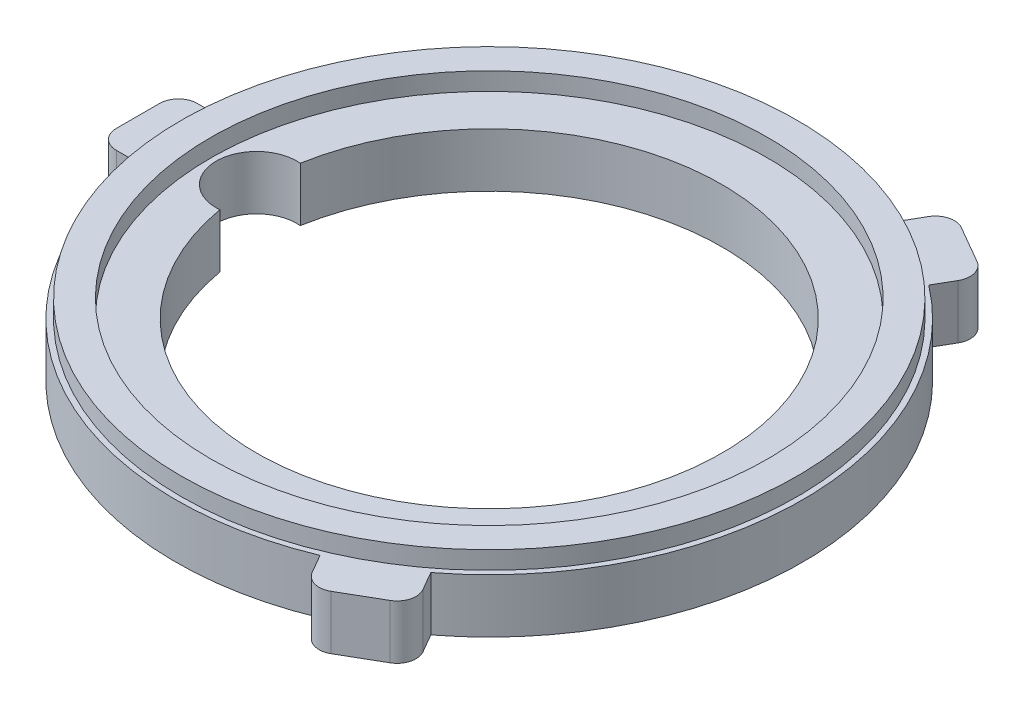
from build123d import *

# Parameters (mm, degrees)
SKIZZE1_R                       = 5.8
AUFSATZ_LINEAR_AUSTRAGEN1_DEPTH = 1
SKIZZE1_3_W                     = 1.261937381
SKIZZE1_3_H                     = 1.5
AUFSATZ_LINEAR_AUSTRAGEN2_DEPTH = 1
SKIZZE4_R                       = 4.304974062
SCHNITT_LINEAR_AUSTRAGEN1_DEPTH = 1
SKIZZE5_R                       = 0.747652737
SCHNITT_LINEAR_AUSTRAGEN2_DEPTH = 1
KREISMUSTER1_COUNT              = 3
VERRUNDUNG2_R                   = 0.35
SKIZZE6_R                       = 5.7
SKIZZE6_R_2                     = 5.1526268
AUFSATZ_LINEAR_AUSTRAGEN3_DEPTH = 0.33


with BuildPart() as part:
    # Skizze1 → Aufsatz-Linear austragen1 (new body)
    with BuildSketch(Plane(origin=(0, 0, 0), x_dir=(1, 0, 0), z_dir=(0, 1, 0))):
        Circle(SKIZZE1_R)
    extrude(amount=AUFSATZ_LINEAR_AUSTRAGEN1_DEPTH)

    # Skizze1_3 → Aufsatz-Linear austragen2 (add)
    with BuildSketch(Plane(origin=(0, 0, 0), x_dir=(1, 0, 0), z_dir=(0, 1, 0))):
        with Locations((-5.86903131, 0)):
            Rectangle(SKIZZE1_3_W, SKIZZE1_3_H)
    aufsatz_linear_austragen2 = extrude(amount=AUFSATZ_LINEAR_AUSTRAGEN2_DEPTH)

    # Skizze4 → Schnitt-Linear austragen1 (cut)
    with BuildSketch(Plane(origin=(0, 1, 0), x_dir=(1, 0, 0), z_dir=(0, 1, 0))):
        Circle(SKIZZE4_R)
    extrude(amount=-SCHNITT_LINEAR_AUSTRAGEN1_DEPTH, mode=Mode.SUBTRACT)

    # Skizze5 → Schnitt-Linear austragen2 (cut)
    with BuildSketch(Plane(origin=(0, 1, 0), x_dir=(1, 0, 0), z_dir=(0, 1, 0))):
        with Locations((-4.304974062, 0)):
            Circle(SKIZZE5_R)
    extrude(amount=-SCHNITT_LINEAR_AUSTRAGEN2_DEPTH, mode=Mode.SUBTRACT)

    # Kreismuster1: Aufsatz-Linear austragen2 ×3 about axis
    kreismuster1_axis = Axis((0, 0, 0), (0, 1, 0))
    for i in range(1, KREISMUSTER1_COUNT):
        add(aufsatz_linear_austragen2.rotate(kreismuster1_axis, i * 360 / KREISMUSTER1_COUNT))

    # Verrundung2
    verrundung2_edges = [part.edges().sort_by_distance(p)[0] for p in [
        (2.600480947, 0.5, 6.004165125),
        (3.899519053, 0.5, 5.254165125),
        (3.899519053, 0.5, -5.254165125),
        (2.600480947, 0.5, -6.004165125),
        (-6.5, 0.5, 0.75),
        (-6.5, 0.5, -0.75),
    ]]
    fillet(verrundung2_edges, radius=VERRUNDUNG2_R)

    # Skizze6 → Aufsatz-Linear austragen3 (add)
    with BuildSketch(Plane(origin=(0, 1, 0), x_dir=(1, 0, 0), z_dir=(0, 1, 0))):
        Circle(SKIZZE6_R)
        Circle(SKIZZE6_R_2, mode=Mode.SUBTRACT)
    extrude(amount=AUFSATZ_LINEAR_AUSTRAGEN3_DEPTH)


solid = part.part
